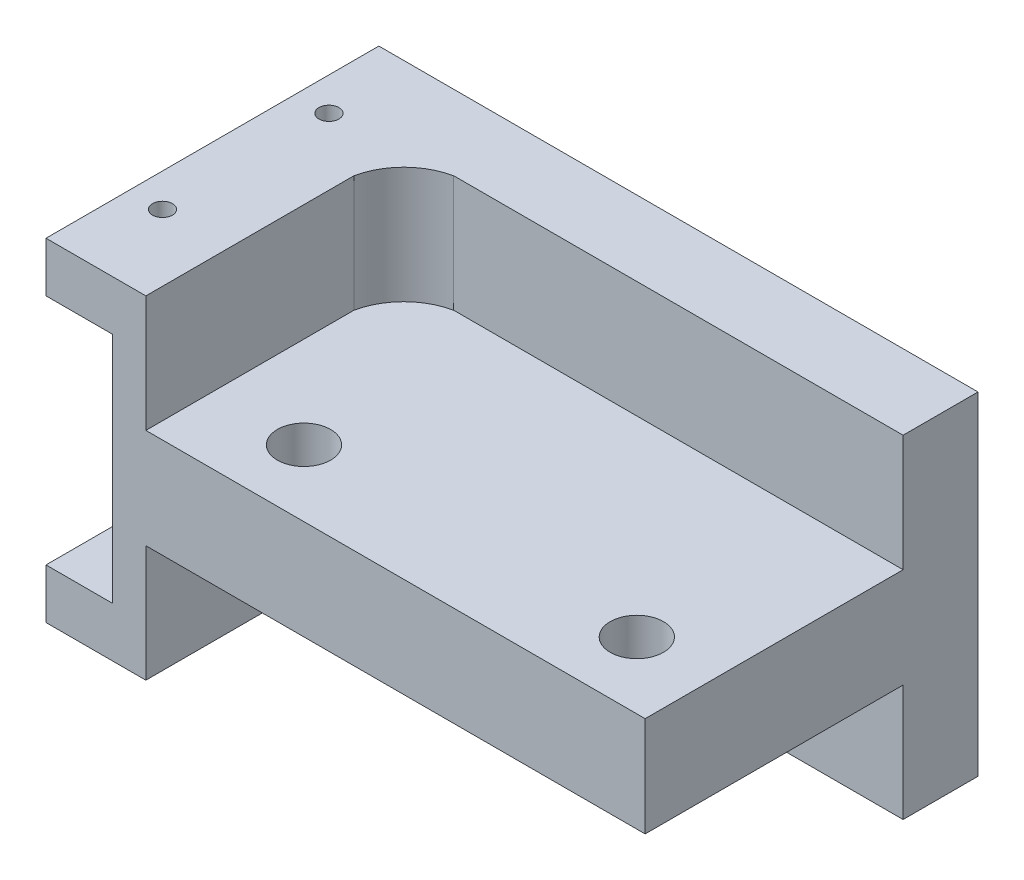
from build123d import *

# Parameters (mm, degrees)
SKETCH1_W           = 35
SKETCH1_H           = 20
BOSS_EXTRUDE2_DEPTH = 10
CUT_EXTRUDE1_DEPTH  = 7
CUT_EXTRUDE2_DEPTH  = 7
SKETCH8_R           = 1.6
CUT_EXTRUDE3_DEPTH  = 7
SKETCH9_W           = 20
SKETCH9_H           = 14
CUT_EXTRUDE4_DEPTH  = 3
SKETCH10_R          = 0.6
CUT_EXTRUDE5_DEPTH  = 3
SKETCH11_R          = 0.6
CUT_EXTRUDE6_DEPTH  = 3
SKETCH12_W          = 20
SKETCH12_H          = 3
BOSS_EXTRUDE3_DEPTH = 1
SKETCH13_W          = 20
SKETCH13_H          = 3
BOSS_EXTRUDE4_DEPTH = 1


with BuildPart() as part:
    # Sketch1 → Boss-Extrude2 (new body, symmetric)
    with BuildSketch(Plane(origin=(0, 0, 0), x_dir=(1, 0, 0), z_dir=(0, 1, 0))):
        Rectangle(SKETCH1_W, SKETCH1_H)
    extrude(amount=BOSS_EXTRUDE2_DEPTH, both=True)

    # Sketch4 → Cut-Extrude1 (cut)
    with BuildSketch(Plane(origin=(0, 10, 0), x_dir=(1, 0, 0), z_dir=(0, 1, 0))):
        with BuildLine():
            Line((-12.5, -10), (-12.5, 2.5))
            ThreePointArc((-12.5, 2.5), (-11.447225408, 4.447225408), (-9.5, 5.5))
            Line((-9.5, 5.5), (17.5, 5.5))
            Line((17.5, 5.5), (17.5, -10))
            Line((17.5, -10), (-12.5, -10))
        make_face()
    extrude(amount=-CUT_EXTRUDE1_DEPTH, mode=Mode.SUBTRACT)

    # Sketch6 → Cut-Extrude2 (cut)
    with BuildSketch(Plane.XZ.offset(10)):
        with BuildLine():
            Line((-12.5, 10), (-12.5, -2.5))
            ThreePointArc((-12.5, -2.5), (-11.528297563, -4.528297563), (-9.5, -5.5))
            Line((-9.5, -5.5), (17.5, -5.5))
            Line((17.5, -5.5), (17.5, 10))
            Line((17.5, 10), (-12.5, 10))
        make_face()
    extrude(amount=-CUT_EXTRUDE2_DEPTH, mode=Mode.SUBTRACT)

    # Sketch8 → Cut-Extrude3 (cut)
    with BuildSketch(Plane(origin=(0, 3, 0), x_dir=(1, 0, 0), z_dir=(0, 1, 0))):
        with Locations((-7, -6)):
            Circle(SKETCH8_R)
        with Locations((13, -6)):
            Circle(SKETCH8_R)
    extrude(amount=-CUT_EXTRUDE3_DEPTH, mode=Mode.SUBTRACT)

    # Sketch9 → Cut-Extrude4 (cut)
    with BuildSketch(Plane.ZY.offset(17.5)):
        Rectangle(SKETCH9_W, SKETCH9_H)
    extrude(amount=-CUT_EXTRUDE4_DEPTH, mode=Mode.SUBTRACT)

    # Sketch10 → Cut-Extrude5 (cut)
    with BuildSketch(Plane(origin=(0, 10, 0), x_dir=(1, 0, 0), z_dir=(0, 1, 0))):
        with Locations((-16.5, 5)):
            Circle(SKETCH10_R)
        with Locations((-16.5, -5)):
            Circle(SKETCH10_R)
    extrude(amount=-CUT_EXTRUDE5_DEPTH, mode=Mode.SUBTRACT)

    # Sketch11 → Cut-Extrude6 (cut)
    with BuildSketch(Plane.XZ.offset(10)):
        with Locations((-16.5, 5)):
            Circle(SKETCH11_R)
        with Locations((-16.5, -5)):
            Circle(SKETCH11_R)
    extrude(amount=-CUT_EXTRUDE6_DEPTH, mode=Mode.SUBTRACT)

    # Sketch12 → Boss-Extrude3 (add)
    with BuildSketch(Plane.ZY.offset(17.5)):
        with Locations((0, 8.5)):
            Rectangle(SKETCH12_W, SKETCH12_H)
    extrude(amount=BOSS_EXTRUDE3_DEPTH)

    # Sketch13 → Boss-Extrude4 (add)
    with BuildSketch(Plane.ZY.offset(17.5)):
        with Locations((0, -8.5)):
            Rectangle(SKETCH13_W, SKETCH13_H)
    extrude(amount=BOSS_EXTRUDE4_DEPTH)


solid = part.part
